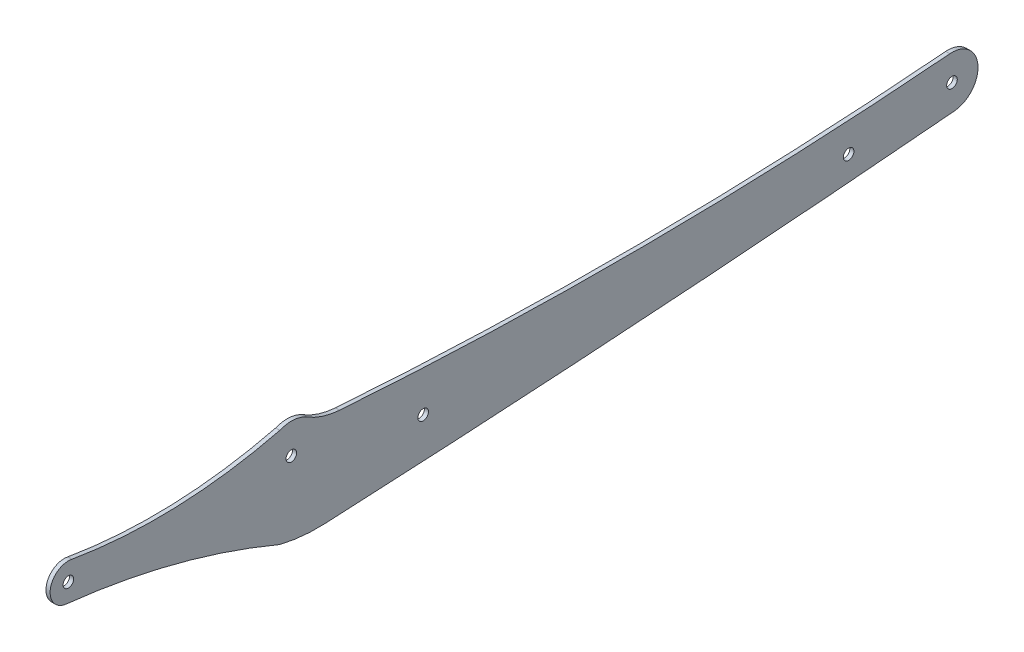
from build123d import *

# Parameters (mm, degrees)
SKETCH_1_R      = 1.925
EXTRUDE_1_DEPTH = 1.5


with BuildPart() as part:
    # 草圖1 → 填料-伸長1 (new body)
    with BuildSketch(Plane(origin=(0, 0, 0), x_dir=(0, 0, -1), z_dir=(1, 0, 0))):
        with BuildLine():
            ThreePointArc((-130.897263822, 87.591071909), (-168.871615346, 100.442909595), (-208.309414447, 107.64576373))
            ThreePointArc((-208.309414447, 107.64576373), (-214.28117701, 115.199320657), (-206.405854958, 120.739850681))
            ThreePointArc((-206.405854958, 120.739850681), (-168.506781938, 118.224744692), (-130.897263822, 123.534136472))
            ThreePointArc((-130.897263822, 123.534136472), (-125.884787037, 124.325252138), (-121.053064598, 122.774366651))
            ThreePointArc((-121.053064598, 122.774366651), (-115.359208766, 120.190083617), (-109.218730551, 119.009812321))
            ThreePointArc((-109.218730551, 119.009812321), (1.650442282, 115.351316794), (112.469361248, 120.30361659))
            ThreePointArc((112.469361248, 120.30361659), (122.671923792, 111.836409472), (114.393924171, 101.479740068))
            ThreePointArc((114.393924171, 101.479740068), (0.082126176, 92.557578457), (-114.38926471, 85.993068006))
            ThreePointArc((-114.38926471, 85.993068006), (-122.70068315, 86.198910651), (-130.897263822, 87.591071909))
        make_face()
        with Locations((113.258391089, 110.873964994)):
            Circle(SKETCH_1_R, mode=Mode.SUBTRACT)
        with Locations((-207.723896624, 114.246052716)):
            Circle(SKETCH_1_R, mode=Mode.SUBTRACT)
        with Locations((-78.841316581, 102.391494034)):
            Circle(SKETCH_1_R, mode=Mode.SUBTRACT)
        with Locations((-126.72836608, 113.395152076)):
            Circle(SKETCH_1_R, mode=Mode.SUBTRACT)
        with Locations((75.716339506, 107.068132225)):
            Circle(SKETCH_1_R, mode=Mode.SUBTRACT)
    extrude(amount=EXTRUDE_1_DEPTH)


solid = part.part
